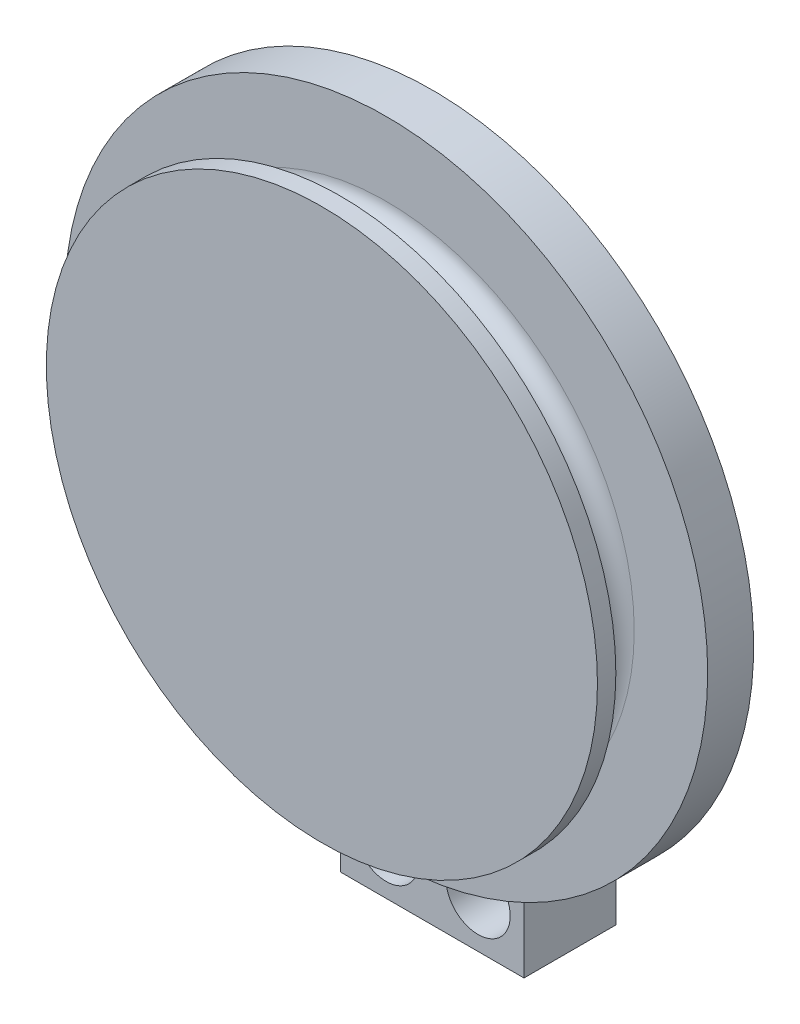
from build123d import *

# Parameters (mm, degrees)
SKETCH1_R               = 4.1
BOSS_EXTRUDE1_DEPTH     = 7
SKETCH2_R               = 6.25
BOSS_EXTRUDE2_DEPTH     = 2
SKETCH3_R               = 35
BOSS_EXTRUDE3_DEPTH     = 5
SKETCH4_R               = 25
BOSS_EXTRUDE4_DEPTH     = 5
SKETCH5_R               = 30
BOSS_EXTRUDE5_DEPTH     = 2
FILLET1_R               = 2
FILLET2_R               = 2
SKETCH6_R               = 1.5
CUT_EXTRUDE1_DEPTH      = 36
CUT_EXTRUDE1_DEPTH_BACK = 36
BOSS_EXTRUDE6_DEPTH     = 10
SKETCH9_R               = 1.75
CUT_EXTRUDE2_DEPTH      = 1
CUT_EXTRUDE2_DEPTH_BACK = 23
SKETCH10_R              = 3.5
CUT_EXTRUDE3_DEPTH      = 6


with BuildPart() as part:
    # Sketch1 → Boss-Extrude1 (new body)
    with BuildSketch(Plane.XY):
        Circle(SKETCH1_R)
    extrude(amount=BOSS_EXTRUDE1_DEPTH)

    # Sketch2 → Boss-Extrude2 (add)
    with BuildSketch(Plane.XY.offset(7)):
        Circle(SKETCH2_R)
    extrude(amount=BOSS_EXTRUDE2_DEPTH)

    # Sketch3 → Boss-Extrude3 (add)
    with BuildSketch(Plane.XY.offset(9)):
        Circle(SKETCH3_R)
    extrude(amount=BOSS_EXTRUDE3_DEPTH)

    # Sketch4 → Boss-Extrude4 (add)
    with BuildSketch(Plane.XY.offset(14)):
        Circle(SKETCH4_R)
    extrude(amount=BOSS_EXTRUDE4_DEPTH)

    # Sketch5 → Boss-Extrude5 (add)
    with BuildSketch(Plane.XY.offset(19)):
        Circle(SKETCH5_R)
    extrude(amount=BOSS_EXTRUDE5_DEPTH)

    # Fillet1
    fillet1_edges = [part.edges().sort_by_distance(p)[0] for p in [
        (-25, 0, 19),
    ]]
    fillet(fillet1_edges, radius=FILLET1_R)

    # Fillet2
    fillet2_edges = [part.edges().sort_by_distance(p)[0] for p in [
        (-25, 0, 14),
    ]]
    fillet(fillet2_edges, radius=FILLET2_R)

    # Sketch6 → Cut-Extrude1 (cut, two sides)
    with BuildSketch(Plane(origin=(0, 0, 0), x_dir=(1, 0, 0), z_dir=(0, 1, 0))) as cut_extrude1_sk:
        with Locations((0.008646323, -16.5)):
            Circle(SKETCH6_R)
    extrude(amount=CUT_EXTRUDE1_DEPTH, mode=Mode.SUBTRACT)
    extrude(cut_extrude1_sk.sketch, amount=-CUT_EXTRUDE1_DEPTH_BACK, mode=Mode.SUBTRACT)

    # Sketch7 → Boss-Extrude6 (add)
    with BuildSketch(Plane(origin=(0, 0, 9), x_dir=(-1, 0, 0), z_dir=(0, 0, -1))):
        with BuildLine():
            Line((35, 0), (27, 0))
            ThreePointArc((27, 0), (15.149257408, -22.349496639), (-10, -25.079872408))
            Line((-10, -25.079872408), (-10, -43.735334875))
            Line((-10, -43.735334875), (10, -43.735334875))
            Line((10, -43.735334875), (10, -33.735334875))
            Line((10, -33.735334875), (10, -33.541019662))
            ThreePointArc((10, -33.541019662), (28.062430401, -20.916500663), (35, 0))
        make_face()
    extrude(amount=BOSS_EXTRUDE6_DEPTH)

    # Sketch9 → Cut-Extrude2 (cut, two sides)
    with BuildSketch(Plane(origin=(0, 0, -1), x_dir=(-1, 0, 0), z_dir=(0, 0, -1))) as cut_extrude2_sk:
        with Locations((5, -38.638177269)):
            Circle(SKETCH9_R)
        with Locations((-5, -38.638177269)):
            Circle(SKETCH9_R)
    extrude(amount=CUT_EXTRUDE2_DEPTH, mode=Mode.SUBTRACT)
    extrude(cut_extrude2_sk.sketch, amount=-CUT_EXTRUDE2_DEPTH_BACK, mode=Mode.SUBTRACT)

    # Sketch10 → Cut-Extrude3 (cut)
    with BuildSketch(Plane.XY.offset(9)):
        with Locations((-5, -38.638177269)):
            Circle(SKETCH10_R)
        with Locations((5, -38.638177269)):
            Circle(SKETCH10_R)
    extrude(amount=-CUT_EXTRUDE3_DEPTH, mode=Mode.SUBTRACT)


solid = part.part
